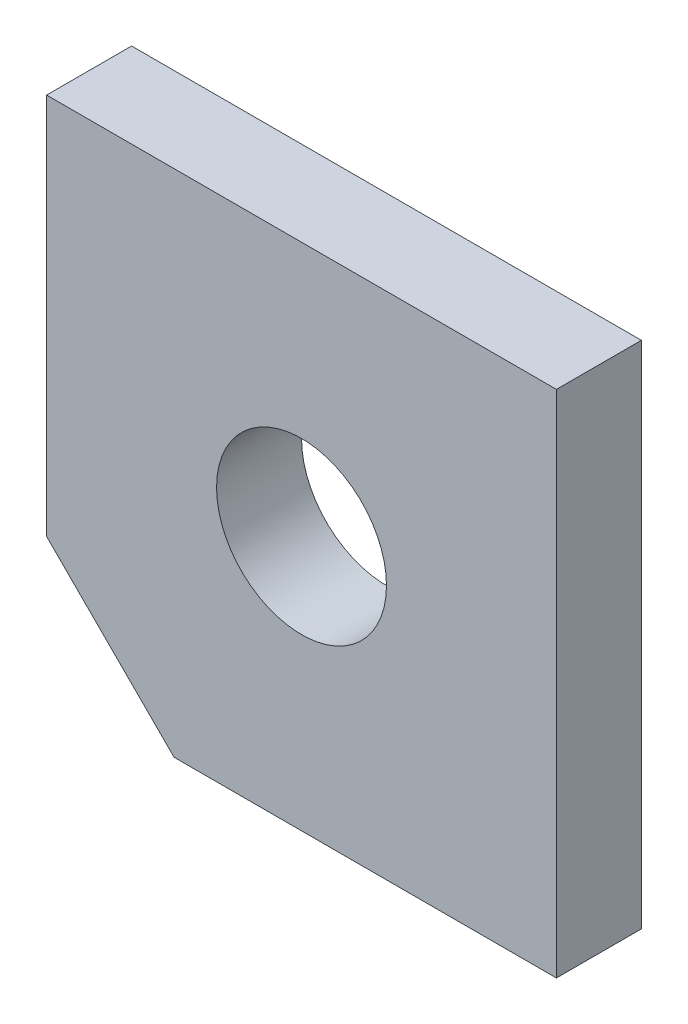
from build123d import *

# Parameters (mm, degrees)
SKETCH1_W           = 76.2
SKETCH1_H           = 76.2
SKETCH1_R           = 12.7
BOSS_EXTRUDE1_DEPTH = 12.7
CHAMFER1_SIZE       = 19.05


with BuildPart() as part:
    # Sketch1 → Boss-Extrude1 (new body)
    with BuildSketch(Plane.XY):
        with Locations((-38.1, 38.1)):
            Rectangle(SKETCH1_W, SKETCH1_H)
        with Locations((-38.1, 38.1)):
            Circle(SKETCH1_R, mode=Mode.SUBTRACT)
    extrude(amount=BOSS_EXTRUDE1_DEPTH)

    # Chamfer1
    chamfer1_edges = [part.edges().sort_by_distance(p)[0] for p in [
        (-76.2, 0, 6.35),
    ]]
    chamfer(chamfer1_edges, length=CHAMFER1_SIZE)


solid = part.part
